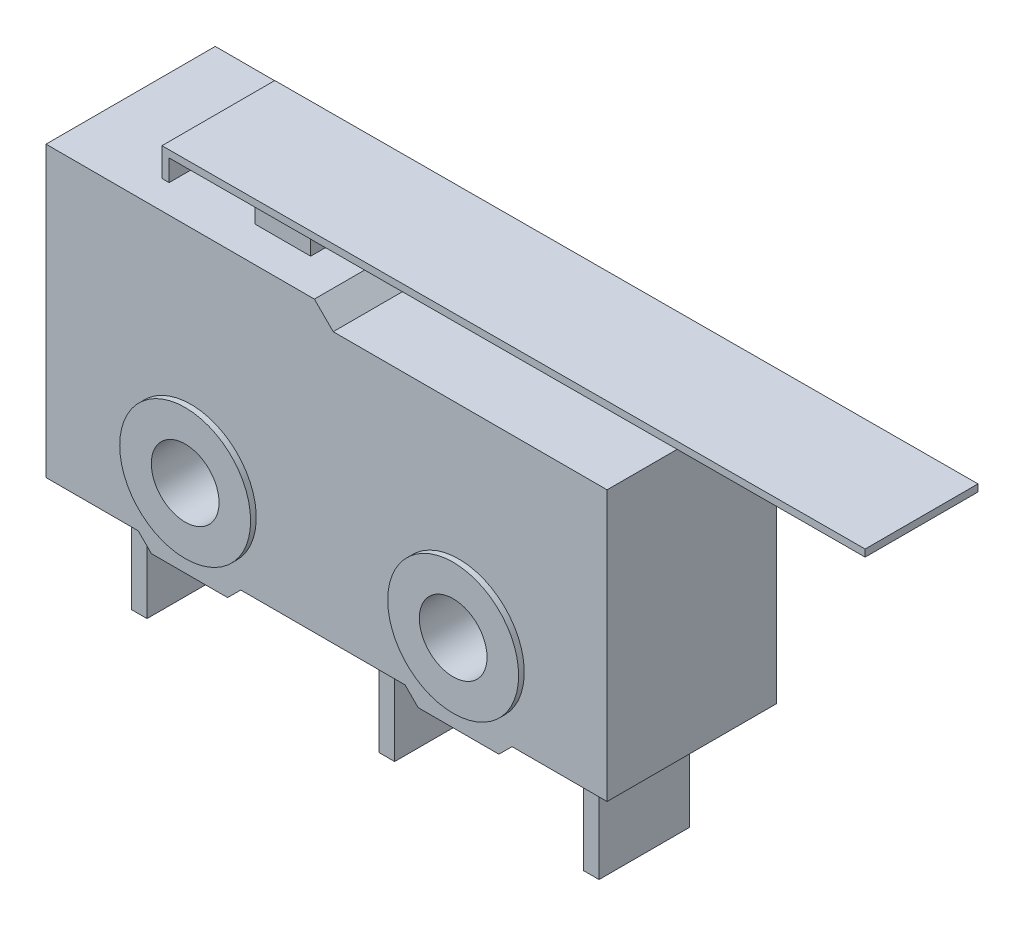
from build123d import *

# Parameters (mm, degrees)
SKETCH2_R             = 1.2
BOSS_EXTRUDE1_DEPTH   = 3
SKETCH3_R             = 2.319639751
SKETCH3_R_2           = 1.2
BOSS_EXTRUDE2_DEPTH   = 3.2
EXTRUDE_THIN1_DEPTH   = 2
BOSS_EXTRUDE3_DEPTH   = 1.75
SKETCH6_W             = 0.546409637
SKETCH6_H             = 3.938984301
BOSS_EXTRUDE4_DEPTH   = 1.6
BOSS_EXTRUDE4_2_DEPTH = 1.6
SKETCH6_W_2           = 0.546409636
BOSS_EXTRUDE4_3_DEPTH = 1.6


with BuildPart() as part:
    # Sketch2 → Boss-Extrude1 (new body, symmetric)
    with BuildSketch(Plane.XY):
        Polygon((-5.132917841, -2.498802599), (-1.863393107, -2.498802599), (-1.397707667, -2.964488039), (1.304774393, -2.964488039), (1.770459833, -2.498802599), (7.594789334, -2.498802599), (8.060474774, -2.964488039), (10.920734529, -2.964488039), (11.386419969, -2.498802599), (14.75505715, -2.498802599), (14.75505715, 7.069677676), (5.047500126, 7.069677676), (4.379931735, 7.737246067), (-5.132917841, 7.737246067), align=None)
        Circle(SKETCH2_R, mode=Mode.SUBTRACT)
        with Locations((9.5, 0)):
            Circle(SKETCH2_R, mode=Mode.SUBTRACT)
    extrude(amount=BOSS_EXTRUDE1_DEPTH, both=True)

    # Sketch3 → Boss-Extrude2 (add, symmetric)
    with BuildSketch(Plane.XY):
        Circle(SKETCH3_R)
        Circle(SKETCH3_R_2, mode=Mode.SUBTRACT)
        with Locations((9.5, 0)):
            Circle(SKETCH3_R)
        with Locations((9.5, 0)):
            Circle(SKETCH3_R_2, mode=Mode.SUBTRACT)
    extrude(amount=BOSS_EXTRUDE2_DEPTH, both=True)

    # Sketch4 → Boss-Extrude3 (add, symmetric)
    with BuildSketch(Plane.XY):
        Polygon((1.01895614, 7.737246067), (1.01895614, 8.504625171), (2.998833668, 8.511100498), (2.998833668, 7.737246067), align=None)
    extrude(amount=BOSS_EXTRUDE3_DEPTH, both=True)


with BuildPart() as body_2:
    # Sketch5 → Extrude-Thin1 (new body, symmetric)
    with BuildSketch(Plane.XY):
        Polygon((-1.76526318, 6.439708473), (-1.77198678, 8.495497198), (22.902881251, 8.576198069), (22.902063613, 8.826196732), (-2.022803081, 8.744678223), (-2.015261843, 6.438890835), align=None)
    extrude(amount=EXTRUDE_THIN1_DEPTH, both=True)


with BuildPart() as body_3:
    # Sketch6 → Boss-Extrude4 (new body, symmetric)
    with BuildSketch(Plane.XY):
        with Locations((-3.224950656, -4.46829475)):
            Rectangle(SKETCH6_W, SKETCH6_H)
    extrude(amount=BOSS_EXTRUDE4_DEPTH, both=True)


with BuildPart() as body_4:
    # Sketch6 → Boss-Extrude4 2 (new body, symmetric)
    with BuildSketch(Plane.XY):
        with Locations((5.552309937, -4.46829475)):
            Rectangle(SKETCH6_W, SKETCH6_H)
    extrude(amount=BOSS_EXTRUDE4_2_DEPTH, both=True)


with BuildPart() as body_5:
    # Sketch6 → Boss-Extrude4 3 (new body, symmetric)
    with BuildSketch(Plane.XY):
        with Locations((12.797533741, -4.46829475)):
            Rectangle(SKETCH6_W_2, SKETCH6_H)
    extrude(amount=BOSS_EXTRUDE4_3_DEPTH, both=True)


solid = Compound([part.part, body_2.part, body_3.part, body_4.part, body_5.part])
